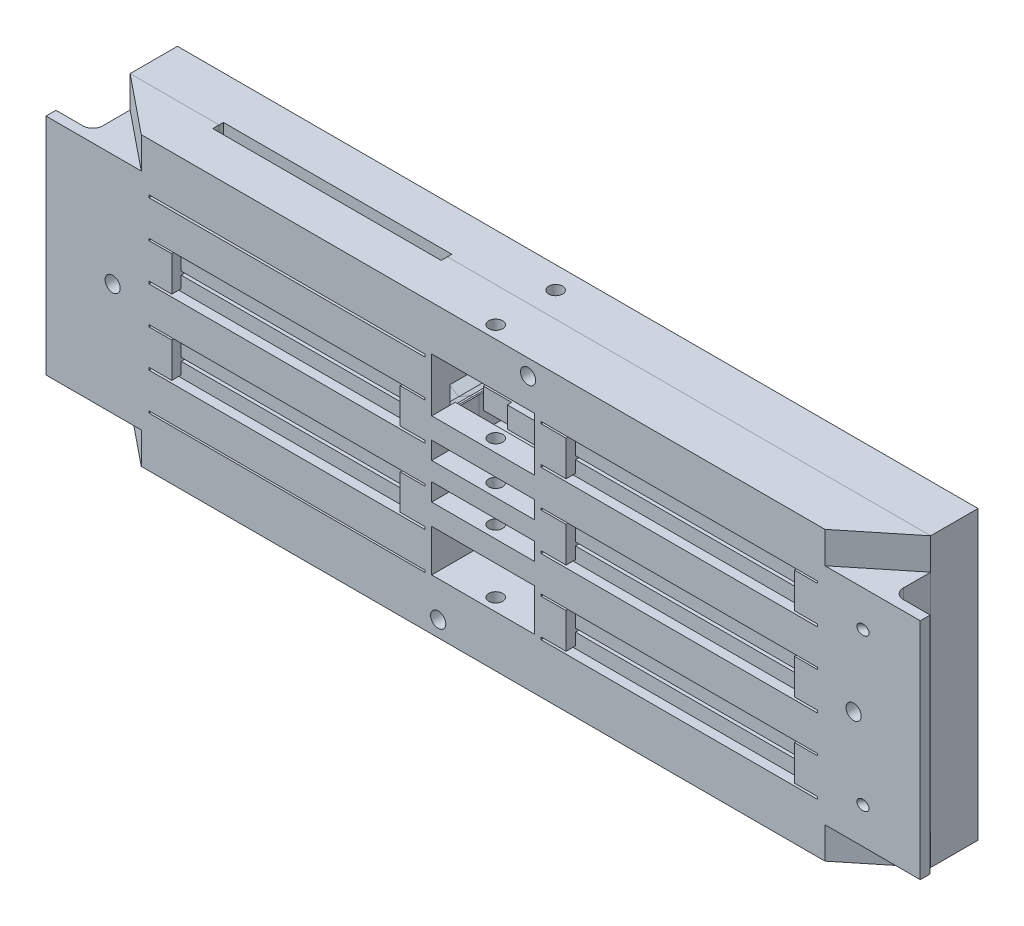
from build123d import *

# Parameters (mm, degrees)
SKETCH1_W                              = 161.21
SKETCH1_H                              = 57.8614
BOTTOM_PLATE_BASE_DEPTH                = 9.525
SKETCH2_W                              = 46
SKETCH2_H                              = 0.7003
SKETCH2_W_2                            = 20.72
SKETCH2_H_2                            = 3.54
THROUGH_HOLES_DEPTH                    = 10.525
SKETCH3_W                              = 57.176
SKETCH3_H                              = 6.62
TOP_SPREADER_CUTS_DEPTH                = 3
TOP_NUT_CUTS_DEPTH                     = 5.8
SKETCH30_R                             = 1.778
TOP_SOCKET_CUTS_DEPTH                  = 2.2544
SKETCH4_W                              = 4.6
SKETCH4_H                              = 0.5
SKETCH4_W_2                            = 5
SKETCH4_H_2                            = 0.4
BOTTOM_CUTS_DEPTH                      = 1.9
LPATTERN1_COUNT                        = 3
LPATTERN1_PITCH                        = 15.0386
SKETCH19_W                             = 20.72
SKETCH19_H                             = 3.54
SKETCH19_W_2                           = 70.245
SKETCH19_H_2                           = 13.920778117
END_FILLER_DEPTH                       = 9.525
TOP_END_SPREADER_CUTS_DEPTH            = 3
TOP_END_NUT_CUTS_DEPTH                 = 5.8
SKETCH32_R                             = 1.778
TOP_END_SOCKET_CUTS_DEPTH              = 2.2544
SKETCH15_W                             = 46
SKETCH15_H                             = 3.2783
SKETCH15_H_2                           = 3.6331
END_BUS_BAR_CUTS_DEPTH                 = 1.27
SKETCH13_W                             = 46
SKETCH13_H                             = 0.4
SKETCH13_W_2                           = 20.72
SKETCH13_H_2                           = 4.93
SKETCH13_H_3                           = 0.5
SKETCH13_H_4                           = 5.87
END_THROUGH_HOLES_DEPTH                = 10.525
SKETCH28_W                             = 55.6
SKETCH28_H                             = 0.4
SKETCH28_H_2                           = 0.5
BOTTOM_END_CUTS_DEPTH                  = 1.9
COVER_START                            = -2
COVER_CONNECTING_NUT_HOLE_1_DEPTH      = 3.7
COVER_CONNECTING_NUT_HOLE_2_DEPTH      = 5.7
SKETCH16_W                             = 20.72
SKETCH16_H                             = 38.5472
BMS_BOARD_CLEARANCE_DEPTH              = 4.773
BOTTOM_PLATE_SIDE_CUTS_DEPTH           = 6.35
SKETCH23_W                             = 161.21
SKETCH23_H                             = 57.8614
LOWER_TOP_PLATE_DEPTH                  = 7.747
SKETCH37_W                             = 5.71
SKETCH37_H                             = 3.8204
SKETCH37_H_2                           = 4.3382
SKETCH37_W_2                           = 46
SKETCH37_H_3                           = 3.6331
SKETCH37_H_4                           = 3.2783
LOWER_TOP_PLATE_CUTS_DEPTH             = 0.88
SKETCH25_W                             = 161.21
SKETCH25_H                             = 57.8614
UPPER_TOP_PLATE_DEPTH                  = 1.778
SKETCH39_R                             = 1.525
STACK_MOUNTING_SOCKET_HOLES_DEPTH      = 20.05
SKETCH40_R                             = 2.375
STACK_MOUNTING_SOCKET_HEAD_HOLES_DEPTH = 2.9
SKETCH18_R                             = 1.397
SKETCH18_R_2                           = 1.395
BMS_BOARD_MOUNTING_HOLES_DEPTH         = 58.8614
SKETCH38_R                             = 1
END_CELL_BOARD_HOLES_DEPTH             = 93.466257304
END_CELL_BOARD_HOLES_DEPTH_BACK        = 16.604846444
SKETCH46_W                             = 7.4199
SKETCH46_H                             = 45.1614
CELL_SIDE_OVERLAP_EXTRUSION_DEPTH      = 2
CELL_SIDE_OVERLAP_FILLET_R             = 2


with BuildPart() as part:
    # Sketch1 → Bottom Plate Base (new body)
    with BuildSketch(Plane.XY):
        Rectangle(SKETCH1_W, SKETCH1_H)
    extrude(amount=BOTTOM_PLATE_BASE_DEPTH)

    # Sketch2 → Through Holes (cut, through all)
    with BuildSketch(Plane(origin=(0, 0, 0), x_dir=(-1, 0, 0), z_dir=(0, 0, -1))):
        with Locations((-39.7001, -15.66135)):
            Rectangle(SKETCH2_W, SKETCH2_H)
        with Locations((39.6999, -23.18065)):
            Rectangle(SKETCH2_W, SKETCH2_H)
        with Locations((0, -11.919)):
            Rectangle(SKETCH2_W_2, SKETCH2_H_2)
        with Locations((0, -19.1794)):
            Rectangle(SKETCH2_W_2, SKETCH2_H_2)
    through_holes = extrude(amount=-THROUGH_HOLES_DEPTH, mode=Mode.SUBTRACT)

    # Sketch3 → Top Spreader Cuts (cut)
    with BuildSketch(Plane.XY):
        with Locations((39.7001, -12.1924)):
            Rectangle(SKETCH3_W, SKETCH3_H)
        with Locations((-39.6999, -19.7002)):
            Rectangle(SKETCH3_W, SKETCH3_H)
    top_spreader_cuts = extrude(amount=TOP_SPREADER_CUTS_DEPTH, mode=Mode.SUBTRACT)

    # Sketch26 → Top Nut Cuts (cut)
    with BuildSketch(Plane(origin=(0, 0, 0), x_dir=(-1, 0, 0), z_dir=(0, 0, -1))):
        Polygon((69.0279, -17.36193141), (64.9779, -15.02366282), (60.9279, -17.36193141), (60.9279, -22.03846859), (64.9779, -24.37673718), (69.0279, -22.03846859), align=None)
        Polygon((18.4838, -17.355060942), (14.4219, -15.009921883), (10.36, -17.355060942), (10.36, -22.045339058), (14.4219, -24.390478117), (18.4838, -22.045339058), align=None)
        Polygon((-10.36, -9.847145472), (-14.4221, -7.501890943), (-18.4842, -9.847145472), (-18.4842, -14.537654528), (-14.4221, -16.882909057), (-10.36, -14.537654528), align=None)
        Polygon((-60.9281, -9.85413141), (-64.9781, -7.51586282), (-69.0281, -9.85413141), (-69.0281, -14.53066859), (-64.9781, -16.86893718), (-60.9281, -14.53066859), align=None)
    top_nut_cuts = extrude(amount=-TOP_NUT_CUTS_DEPTH, mode=Mode.SUBTRACT)

    # Sketch30 → Top Socket Cuts (cut)
    with BuildSketch(Plane(origin=(0, 0, 5.8), x_dir=(-1, 0, 0), z_dir=(0, 0, -1))):
        with Locations((-64.9781, -12.1924)):
            Circle(SKETCH30_R)
        with Locations((-14.4221, -12.1924)):
            Circle(SKETCH30_R)
        with Locations((14.4219, -19.7002)):
            Circle(SKETCH30_R)
        with Locations((64.9779, -19.7002)):
            Circle(SKETCH30_R)
    top_socket_cuts = extrude(amount=-TOP_SOCKET_CUTS_DEPTH, mode=Mode.SUBTRACT)

    # Sketch4 → Bottom Cuts (cut)
    with BuildSketch(Plane.XY.offset(9.525)):
        with Locations((-64.9999, -26.154)):
            Rectangle(SKETCH4_W, SKETCH4_H)
        Polygon((-16.6999, -18.4571), (-62.6999, -18.4571), (-62.6999, -18.8571), (-62.6999, -22.8305), (-16.6999, -22.8305), (-16.6999, -18.8571), align=None)
        Polygon((-16.6999, -23.5308), (-62.6999, -23.5308), (-62.6999, -25.904), (-62.6999, -26.404), (-16.6999, -26.404), (-16.6999, -25.904), align=None)
        with Locations((-14.1999, -18.6571)):
            Rectangle(SKETCH4_W_2, SKETCH4_H_2)
        with Locations((-14.1999, -26.154)):
            Rectangle(SKETCH4_W_2, SKETCH4_H)
        Polygon((62.7001, -16.0115), (16.7001, -16.0115), (16.7001, -18.4073), (16.7001, -18.9073), (62.7001, -18.9073), (62.7001, -18.4073), align=None)
        Polygon((62.7001, -10.9154), (16.7001, -10.9154), (16.7001, -11.3154), (16.7001, -15.3112), (62.7001, -15.3112), (62.7001, -11.3154), align=None)
        with Locations((14.2001, -11.1154)):
            Rectangle(SKETCH4_W_2, SKETCH4_H_2)
        with Locations((65.0001, -11.1154)):
            Rectangle(SKETCH4_W, SKETCH4_H_2)
        with Locations((65.0001, -18.6573)):
            Rectangle(SKETCH4_W, SKETCH4_H)
        with Locations((-64.9999, -18.6571)):
            Rectangle(SKETCH4_W, SKETCH4_H_2)
        with Locations((14.2001, -18.6573)):
            Rectangle(SKETCH4_W_2, SKETCH4_H)
    bottom_cuts = extrude(amount=-BOTTOM_CUTS_DEPTH, mode=Mode.SUBTRACT)

    # LPattern1: Through Holes, Top Spreader Cuts, Top Nut Cuts, Top Socket Cuts, Bottom Cuts ×3
    with Locations(*[(0, i * LPATTERN1_PITCH, 0) for i in range(1, LPATTERN1_COUNT)]):
        add(through_holes, mode=Mode.SUBTRACT)
        add(top_spreader_cuts, mode=Mode.SUBTRACT)
        add(top_nut_cuts, mode=Mode.SUBTRACT)
        add(top_socket_cuts, mode=Mode.SUBTRACT)
        add(bottom_cuts, mode=Mode.SUBTRACT)

    # Sketch19 → End Filler (add)
    with BuildSketch(Plane(origin=(0, 0, 0), x_dir=(-1, 0, 0), z_dir=(0, 0, -1))):
        with Locations((0, -19.1794)):
            Rectangle(SKETCH19_W, SKETCH19_H)
        with Locations((45.4825, -21.970310942)):
            Rectangle(SKETCH19_W_2, SKETCH19_H_2)
    extrude(amount=-END_FILLER_DEPTH)

    # Sketch20 → Top End Spreader Cuts (cut)
    with BuildSketch(Plane(origin=(0, 0, 0), x_dir=(-1, 0, 0), z_dir=(0, 0, -1))):
        Polygon((11.1119, -25.2976), (11.1119, -18.6776), (16.6999, -18.6776), (16.6999, -18.8573), (62.6999, -18.8573), (62.6999, -18.6776), (68.2879, -18.6776), (68.2879, -25.2976), align=None)
        Polygon((62.6999, 19.2121), (62.6999, 19.0324), (68.2879, 19.0324), (68.2879, 25.6524), (11.1119, 25.6524), (11.1119, 19.0324), (16.6999, 19.0324), (16.6999, 19.2121), align=None)
    extrude(amount=-TOP_END_SPREADER_CUTS_DEPTH, mode=Mode.SUBTRACT)

    # Sketch31 → Top End Nut Cuts (cut)
    with BuildSketch(Plane(origin=(0, 0, 0), x_dir=(-1, 0, 0), z_dir=(0, 0, -1))):
        Polygon((69.0279, -19.64933141), (64.9779, -17.31106282), (60.9279, -19.64933141), (60.9279, -24.32586859), (64.9779, -26.66413718), (69.0279, -24.32586859), align=None)
        Polygon((18.4838, -19.642460942), (14.4219, -17.297321883), (10.36, -19.642460942), (10.36, -24.332739058), (14.4219, -26.677878117), (18.4838, -24.332739058), align=None)
        Polygon((69.0279, 24.68066859), (64.9779, 27.01893718), (60.9279, 24.68066859), (60.9279, 20.00413141), (64.9779, 17.66586282), (69.0279, 20.00413141), align=None)
        Polygon((18.4838, 24.687539058), (14.4219, 27.032678117), (10.36, 24.687539058), (10.36, 19.997260942), (14.4219, 17.652121883), (18.4838, 19.997260942), align=None)
    extrude(amount=-TOP_END_NUT_CUTS_DEPTH, mode=Mode.SUBTRACT)

    # Sketch32 → Top End Socket Cuts (cut)
    with BuildSketch(Plane(origin=(0, 0, 5.8), x_dir=(-1, 0, 0), z_dir=(0, 0, -1))):
        with Locations((14.4219, -21.9876)):
            Circle(SKETCH32_R)
        with Locations((64.9779, -21.9876)):
            Circle(SKETCH32_R)
        with Locations((14.4219, 22.3424)):
            Circle(SKETCH32_R)
        with Locations((64.9779, 22.3424)):
            Circle(SKETCH32_R)
    extrude(amount=-TOP_END_SOCKET_CUTS_DEPTH, mode=Mode.SUBTRACT)

    # Sketch15 → End Bus Bar Cuts (cut)
    with BuildSketch(Plane(origin=(0, 0, 0), x_dir=(-1, 0, 0), z_dir=(0, 0, -1))):
        with Locations((39.6999, 27.29155)):
            Rectangle(SKETCH15_W, SKETCH15_H)
        with Locations((39.6999, -27.11415)):
            Rectangle(SKETCH15_W, SKETCH15_H_2)
    extrude(amount=-END_BUS_BAR_CUTS_DEPTH, mode=Mode.SUBTRACT)

    # Sketch13 → End Through Holes (cut, through all)
    with BuildSketch(Plane(origin=(0, 0, 0), x_dir=(-1, 0, 0), z_dir=(0, 0, -1))):
        with Locations((39.6999, -18.6573)):
            Rectangle(SKETCH13_W, SKETCH13_H)
        with Locations((0, -16.154)):
            Rectangle(SKETCH13_W_2, SKETCH13_H_2)
        with Locations((39.6999, 18.9621)):
            Rectangle(SKETCH13_W, SKETCH13_H_3)
        with Locations((0, 15.6028)):
            Rectangle(SKETCH13_W_2, SKETCH13_H_4)
    extrude(amount=-END_THROUGH_HOLES_DEPTH, mode=Mode.SUBTRACT)

    # Sketch28 → Bottom End Cuts (cut)
    with BuildSketch(Plane.XY.offset(9.525)):
        with Locations((-39.4999, -18.6573)):
            Rectangle(SKETCH28_W, SKETCH28_H)
        with Locations((-39.4999, 18.9621)):
            Rectangle(SKETCH28_W, SKETCH28_H_2)
    extrude(amount=-BOTTOM_END_CUTS_DEPTH, mode=Mode.SUBTRACT)

    # Sketch41 → Cover Connecting Nut Hole 1 (cut)
    with BuildSketch(Plane(origin=(0, 0, 0), x_dir=(-1, 0, 0), z_dir=(0, 0, -1)).offset(COVER_START)):
        Polygon((-73.747562584, -3.2), (-75.462437416, -3.2), (-74.605, -3.695041723), align=None)
        Polygon((-77.805, -1.847520861), (-75.462437416, -3.2), (-73.747562584, -3.2), (-71.405, -1.847520861), (-71.405, 1.847520861), (-73.747562584, 3.2), (-75.462437416, 3.2), (-77.805, 1.847520861), align=None)
        Polygon((-77.805, 3.2), (-77.805, 1.847520861), (-75.462437416, 3.2), align=None)
        Polygon((-73.747562584, 3.2), (-71.405, 1.847520861), (-71.405, 3.2), align=None)
        Polygon((75.462437416, -3.2), (73.747562584, -3.2), (74.605, -3.695041723), align=None)
        Polygon((71.405, -1.847520861), (73.747562584, -3.2), (75.462437416, -3.2), (77.805, -1.847520861), (77.805, 1.847520861), (75.462437416, 3.2), (73.747562584, 3.2), (71.405, 1.847520861), align=None)
        Polygon((71.405, 3.2), (71.405, 1.847520861), (73.747562584, 3.2), align=None)
        Polygon((75.462437416, 3.2), (77.805, 1.847520861), (77.805, 3.2), align=None)
    extrude(amount=-COVER_CONNECTING_NUT_HOLE_1_DEPTH, mode=Mode.SUBTRACT)

    # Sketch42 → Cover Connecting Nut Hole 2 (cut)
    with BuildSketch(Plane(origin=(0, 0, 0), x_dir=(-1, 0, 0), z_dir=(0, 0, -1))):
        Polygon((-78.605, 3.2), (-77.805, 3.2), (-71.405, 3.2), (-70.605, 3.2), (-70.605, 11.2), (-78.605, 11.2), align=None)
        Polygon((70.605, 3.2), (71.405, 3.2), (77.805, 3.2), (78.605, 3.2), (78.605, 11.2), (70.605, 11.2), align=None)
    extrude(amount=-COVER_CONNECTING_NUT_HOLE_2_DEPTH, mode=Mode.SUBTRACT)

    # Sketch16 → BMS Board Clearance (cut)
    with BuildSketch(Plane(origin=(0, 0, 0), x_dir=(-1, 0, 0), z_dir=(0, 0, -1))):
        with Locations((0, 0.6546)):
            Rectangle(SKETCH16_W, SKETCH16_H)
    extrude(amount=-BMS_BOARD_CLEARANCE_DEPTH, mode=Mode.SUBTRACT)

    # Sketch45 → Bottom Plate Side Cuts (cut)
    with BuildSketch(Plane.XZ.offset(28.9307)):
        Polygon((80.605, 0), (68.842604584, 9.525), (80.605, 9.525), align=None)
        Polygon((-80.605, 0), (-80.605, 9.525), (-68.842604584, 9.525), align=None)
    bottom_plate_side_cuts = extrude(amount=-BOTTOM_PLATE_SIDE_CUTS_DEPTH, mode=Mode.SUBTRACT)

    # Bottom Plate Sides Lateral Mirror: Bottom Plate Side Cuts across plane
    add(bottom_plate_side_cuts.mirror(Plane.ZX), mode=Mode.SUBTRACT)


with BuildPart() as body_2:
    # Sketch23 → Lower Top Plate (new body)
    with BuildSketch(Plane(origin=(0, 0, 0), x_dir=(-1, 0, 0), z_dir=(0, 0, -1))):
        Rectangle(SKETCH23_W, SKETCH23_H)
        Polygon((62.610988173, -25.2976), (16.812611827, -25.2976), (14.4219, -26.677878117), (12.031188173, -25.2976), (11.1119, -25.2976), (11.1119, -24.766848726), (10.36, -24.332739058), (10.36, -18.619), (-10.36, -18.619), (-10.36, -14.537654528), (-11.1121, -14.971879666), (-11.1121, -15.5024), (-12.030988173, -15.5024), (-14.4221, -16.882909057), (-16.7001, -15.567705144), (-16.7001, -16.0115), (-62.7001, -16.0115), (-62.7001, -15.553733267), (-64.9781, -16.86893718), (-67.345011827, -15.5024), (-68.2881, -15.5024), (-68.2881, -14.957907789), (-69.0281, -14.53066859), (-69.0281, -9.85413141), (-68.2881, -9.426892211), (-68.2881, -8.8824), (-67.345011827, -8.8824), (-64.9781, -7.51586282), (-62.611188173, -8.8824), (-16.813211827, -8.8824), (-14.4221, -7.501890943), (-12.030988173, -8.8824), (-11.1121, -8.8824), (-11.1121, -9.412920334), (-10.36, -9.847145472), (-10.36, -10.149), (10.36, -10.149), (10.36, -17.642460942), (13.824101615, -17.642460942), (14.4219, -17.297321883), (16.6999, -18.612525796), (16.6999, -18.4573), (62.6999, -18.4573), (62.6999, -18.626266733), (64.9779, -17.31106282), (67.344811827, -18.6776), (68.2879, -18.6776), (68.2879, -19.222092211), (69.0279, -19.64933141), (69.0279, -24.32586859), (68.2879, -24.753107789), (68.2879, -25.2976), (67.344811827, -25.2976), (64.9779, -26.66413718), align=None, mode=Mode.SUBTRACT)
        Polygon((-10.36, -5.9108), (-10.36, -2.3708), (10.36, -2.3708), (10.36, -2.316460942), (11.1119, -1.882351274), (11.1119, -1.3516), (12.031188173, -1.3516), (14.4219, 0.028678117), (16.812611827, -1.3516), (62.610988173, -1.3516), (64.9779, 0.01493718), (67.344811827, -1.3516), (68.2879, -1.3516), (68.2879, -1.896092211), (69.0279, -2.32333141), (69.0279, -6.99986859), (68.2879, -7.427107789), (68.2879, -7.9716), (67.344811827, -7.9716), (64.9779, -9.33813718), (62.6999, -8.022933267), (62.6999, -8.4922), (16.6999, -8.4922), (16.6999, -8.036674204), (14.4219, -9.351878117), (12.031188173, -7.9716), (11.1119, -7.9716), (11.1119, -7.440848726), (10.36, -7.006739058), (10.36, -5.9108), align=None, mode=Mode.SUBTRACT)
        Polygon((-10.36, 0.500945472), (-11.1121, 0.066720334), (-11.1121, -0.4638), (-12.030988173, -0.4638), (-14.4221, -1.844309057), (-16.7001, -0.529105144), (-16.7001, -0.9729), (-62.7001, -0.9729), (-62.7001, -0.515133267), (-64.9781, -1.83033718), (-67.345011827, -0.4638), (-68.2881, -0.4638), (-68.2881, 0.080692211), (-69.0281, 0.50793141), (-69.0281, 5.18446859), (-68.2881, 5.611707789), (-68.2881, 6.1562), (-67.345011827, 6.1562), (-64.9781, 7.52273718), (-62.611188173, 6.1562), (-16.813211827, 6.1562), (-14.4221, 7.536709057), (-12.030988173, 6.1562), (-11.1121, 6.1562), (-11.1121, 5.625679666), (-10.36, 5.191454528), (-10.36, 4.8896), (10.36, 4.8896), (10.36, 1.3496), (-10.36, 1.3496), align=None, mode=Mode.SUBTRACT)
        Polygon((-10.36, 9.1278), (-10.36, 15.539545472), (-11.1121, 15.105320334), (-11.1121, 14.5748), (-12.030988173, 14.5748), (-14.4221, 13.194290943), (-16.7001, 14.509494856), (-16.7001, 14.0657), (-62.7001, 14.0657), (-62.7001, 14.523466733), (-64.9781, 13.20826282), (-67.345011827, 14.5748), (-68.2881, 14.5748), (-68.2881, 15.119292211), (-69.0281, 15.54653141), (-69.0281, 20.22306859), (-68.2881, 20.650307789), (-68.2881, 21.1948), (-67.345011827, 21.1948), (-64.9781, 22.56133718), (-62.611188173, 21.1948), (-16.813211827, 21.1948), (-14.4221, 22.575309057), (-12.030988173, 21.1948), (-11.1121, 21.1948), (-11.1121, 20.664279666), (-10.36, 20.230054528), (-10.36, 19.9282), (10.36, 19.9282), (10.36, 24.687539058), (11.1119, 25.121648726), (11.1119, 25.6524), (12.031188173, 25.6524), (14.4219, 27.032678117), (16.812611827, 25.6524), (62.610988173, 25.6524), (64.9779, 27.01893718), (67.344811827, 25.6524), (68.2879, 25.6524), (68.2879, 25.107907789), (69.0279, 24.68066859), (69.0279, 20.00413141), (68.2879, 19.576892211), (68.2879, 19.0324), (67.344811827, 19.0324), (64.9779, 17.66586282), (62.6999, 18.981066733), (62.6999, 18.7121), (16.6999, 18.7121), (16.6999, 18.967325796), (14.4219, 17.652121883), (13.824101615, 17.997260942), (10.36, 17.997260942), (10.36, 12.722139058), (11.1119, 13.156248726), (11.1119, 13.687), (12.031188173, 13.687), (14.4219, 15.067278117), (16.812611827, 13.687), (62.610988173, 13.687), (64.9779, 15.05353718), (67.344811827, 13.687), (68.2879, 13.687), (68.2879, 13.142507789), (69.0279, 12.71526859), (69.0279, 8.03873141), (68.2879, 7.611492211), (68.2879, 7.067), (67.344811827, 7.067), (64.9779, 5.70046282), (62.6999, 7.015666733), (62.6999, 6.5464), (16.6999, 6.5464), (16.6999, 7.001925796), (14.4219, 5.686721883), (12.031188173, 7.067), (11.1119, 7.067), (11.1119, 7.597751274), (10.36, 8.031860942), (10.36, 9.1278), align=None, mode=Mode.SUBTRACT)
    extrude(amount=LOWER_TOP_PLATE_DEPTH)

    # Sketch37 → Lower Top Plate Cuts (cut)
    with BuildSketch(Plane(origin=(0, 0, 0), x_dir=(-1, 0, 0), z_dir=(0, 0, -1))):
        with Locations((-7.505, -0.5606)):
            Rectangle(SKETCH37_W, SKETCH37_H)
        with Locations((7.505, -8.0799)):
            Rectangle(SKETCH37_W, SKETCH37_H_2)
        with Locations((-7.505, 14.4794)):
            Rectangle(SKETCH37_W, SKETCH37_H)
        with Locations((7.505, 6.9601)):
            Rectangle(SKETCH37_W, SKETCH37_H_2)
        with Locations((39.6999, -27.11415)):
            Rectangle(SKETCH37_W_2, SKETCH37_H_3)
        with Locations((39.6999, 27.29155)):
            Rectangle(SKETCH37_W_2, SKETCH37_H_4)
    extrude(amount=LOWER_TOP_PLATE_CUTS_DEPTH, mode=Mode.SUBTRACT)

    # Sketch25 → Upper Top Plate (add)
    with BuildSketch(Plane(origin=(0, 0, -7.747), x_dir=(-1, 0, 0), z_dir=(0, 0, -1))):
        Rectangle(SKETCH25_W, SKETCH25_H)
    extrude(amount=UPPER_TOP_PLATE_DEPTH)


with BuildPart() as stack_mounting_socket_holes_tool:
    # Sketch39 → Stack Mounting Socket Holes (new body, through all)
    with BuildSketch(Plane(origin=(0, 0, -9.525), x_dir=(-1, 0, 0), z_dir=(0, 0, -1))):
        with Locations((-9.0477, 25.7557)):
            Circle(SKETCH39_R)
        with Locations((9.0477, -25.7557)):
            Circle(SKETCH39_R)
        with Locations((74.605, 0)):
            Circle(SKETCH39_R)
        with Locations((-74.605, 0)):
            Circle(SKETCH39_R)
    extrude(amount=-STACK_MOUNTING_SOCKET_HOLES_DEPTH)


with BuildPart() as part_1:
    add(part.part)

    # Stack Mounting Socket Holes: cut by stack_mounting_socket_holes_tool
    add(stack_mounting_socket_holes_tool.part, mode=Mode.SUBTRACT)


with BuildPart() as body_2_1:
    add(body_2.part)

    # Stack Mounting Socket Holes: cut by stack_mounting_socket_holes_tool
    add(stack_mounting_socket_holes_tool.part, mode=Mode.SUBTRACT)

    # Sketch40 → Stack Mounting Socket Head Holes (cut)
    with BuildSketch(Plane(origin=(0, 0, -9.525), x_dir=(-1, 0, 0), z_dir=(0, 0, -1))):
        with Locations((-9.0477, 25.7557)):
            Circle(SKETCH40_R)
        with Locations((74.605, 0)):
            Circle(SKETCH40_R)
        with Locations((9.0477, -25.7557)):
            Circle(SKETCH40_R)
        with Locations((-74.605, 0)):
            Circle(SKETCH40_R)
    extrude(amount=-STACK_MOUNTING_SOCKET_HEAD_HOLES_DEPTH, mode=Mode.SUBTRACT)


with BuildPart() as bms_board_mounting_holes_tool:
    # Sketch18 → BMS Board Mounting Holes (new body, through all)
    with BuildSketch(Plane.XZ.offset(28.9307)):
        with Locations((0, 6.99025)):
            Circle(SKETCH18_R)
        with Locations((0, -5.07975)):
            Circle(SKETCH18_R_2)
    extrude(amount=-BMS_BOARD_MOUNTING_HOLES_DEPTH)


with BuildPart() as part_2:
    add(part_1.part)

    # BMS Board Mounting Holes: cut by bms_board_mounting_holes_tool
    add(bms_board_mounting_holes_tool.part, mode=Mode.SUBTRACT)

    # Sketch38 → End Cell Board Holes (cut, two sides)
    with BuildSketch(Plane(origin=(22.042947067, 0, -31.480590917), x_dir=(0, 1, 0), z_dir=(-0.573576436, 0, 0.819152044))) as end_cell_board_holes_sk:
        with Locations((-15.3207, -68.121066086)):
            Circle(SKETCH38_R)
        with Locations((15.2707, -68.121066086)):
            Circle(SKETCH38_R)
    extrude(amount=END_CELL_BOARD_HOLES_DEPTH, mode=Mode.SUBTRACT)
    extrude(end_cell_board_holes_sk.sketch, amount=-END_CELL_BOARD_HOLES_DEPTH_BACK, mode=Mode.SUBTRACT)

    # Sketch46 → Cell Side Overlap Extrusion (add)
    with BuildSketch(Plane.XY.offset(9.525)):
        with Locations((84.31495, 0)):
            Rectangle(SKETCH46_W, SKETCH46_H)
        with Locations((-84.31495, 0)):
            Rectangle(SKETCH46_W, SKETCH46_H)
    extrude(amount=-CELL_SIDE_OVERLAP_EXTRUSION_DEPTH)

    # Cell Side Overlap Fillet
    cell_side_overlap_fillet_edges = [part_2.edges().sort_by_distance(p)[0] for p in [
        (80.605, 0, 7.525),
        (-80.605, 0, 7.525),
    ]]
    fillet(cell_side_overlap_fillet_edges, radius=CELL_SIDE_OVERLAP_FILLET_R)


with BuildPart() as body_2_2:
    add(body_2_1.part)

    # BMS Board Mounting Holes: cut by bms_board_mounting_holes_tool
    add(bms_board_mounting_holes_tool.part, mode=Mode.SUBTRACT)


solid = Compound([part_2.part, body_2_2.part])
